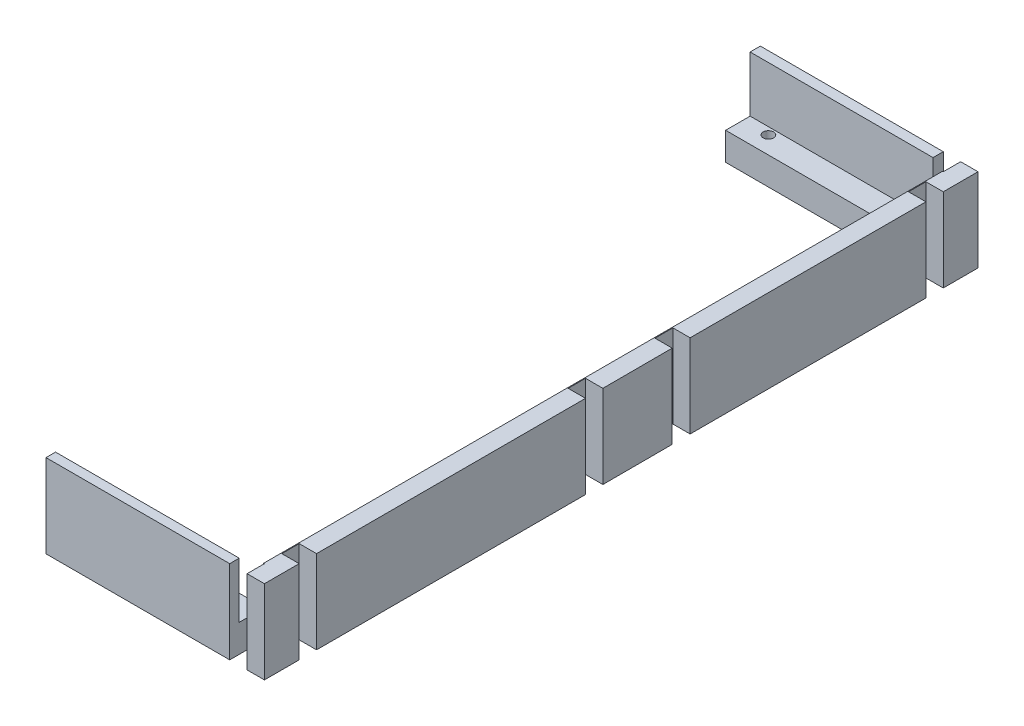
from build123d import *

# Parameters (mm, degrees)
SKETCH2_R           = 1.905
BOSS_EXTRUDE5_DEPTH = 30.48
SKETCH3_W           = 77.139019834
SKETCH3_H           = 253.707230816
CUT_EXTRUDE1_DEPTH  = 20.32


with BuildPart() as part:
    # Sketch2 → Boss-Extrude5 (new body)
    with BuildSketch(Plane(origin=(0, 6.35, 0), x_dir=(1, 0, 0), z_dir=(0, 1, 0))):
        Polygon((37.877734137, 124.478458264), (104.775, 124.478458264), (104.775, 118.128458264), (111.125, 118.128458264), (111.125, 124.478458264), (117.475, 124.478458264), (117.475, 111.778458264), (111.125, 111.778458264), (111.125, 105.428458264), (117.475, 105.428458264), (117.427603838, 19.255527471), (111.125, 19.255527471), (111.125, 12.7), (117.427603838, 12.7), (117.475, -12.7), (111.125, -12.7), (111.125, -19.05), (117.475, -19.05), (117.475, -117.410242597), (111.125, -117.410242597), (111.125, -123.760242597), (117.475, -123.760242597), (117.475, -136.460242597), (111.125, -136.460242597), (111.125, -130.101785028), (104.775, -130.101785028), (104.775, -136.460242597), (37.598341682, -136.460242597), (37.598341682, -123.760242597), (104.775, -123.760242597), (104.775, -111.031020805), (104.775, -24.950677477), (104.775, 19.255527471), (104.775, 25.571960959), (104.775, 99.037268217), (104.775, 105.428458264), (104.775, 111.778458264), (37.877734137, 111.778458264), align=None)
        with Locations((45.623485648, -130.101785028)):
            Circle(SKETCH2_R, mode=Mode.SUBTRACT)
        with Locations((47.180468273, 118.128458264)):
            Circle(SKETCH2_R, mode=Mode.SUBTRACT)
    extrude(amount=BOSS_EXTRUDE5_DEPTH)

    # Sketch3 → Cut-Extrude1 (cut)
    with BuildSketch(Plane(origin=(0, 36.83, 0), x_dir=(1, 0, 0), z_dir=(0, 1, 0))):
        with Locations((72.277192216, -6.116117848)):
            Rectangle(SKETCH3_W, SKETCH3_H)
    extrude(amount=-CUT_EXTRUDE1_DEPTH, mode=Mode.SUBTRACT)


solid = part.part
